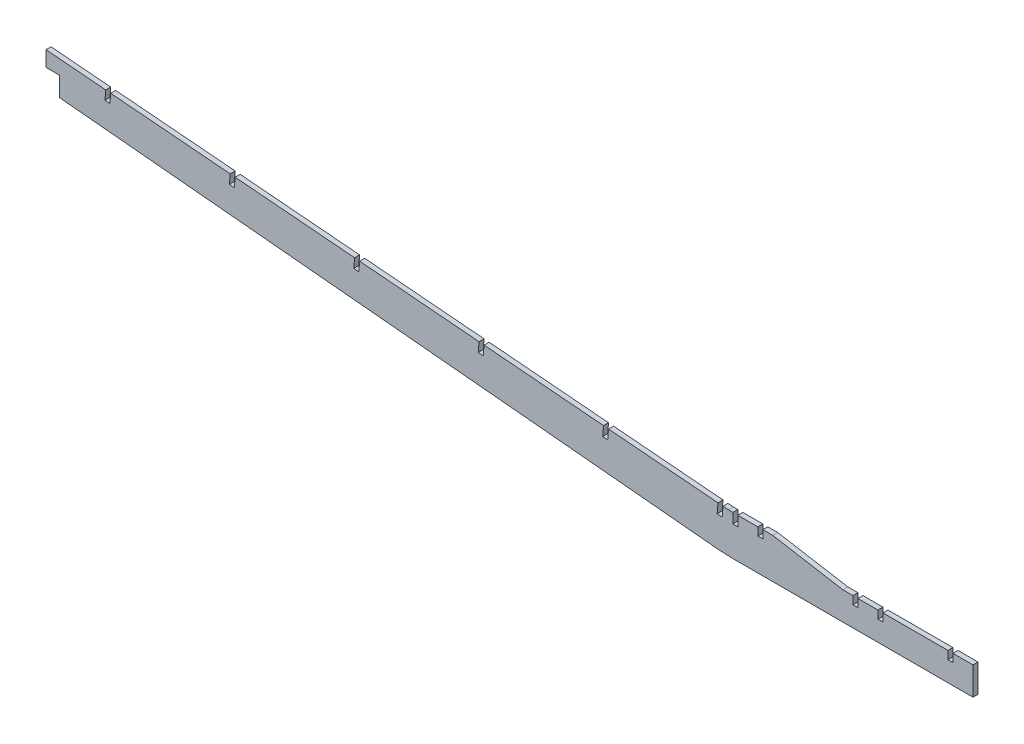
from build123d import *

# Parameters (mm, degrees)
BOSS_EXTRUDE1_DEPTH = 3.175
CUT_EXTRUDE1_DEPTH  = 4.175
CUT_EXTRUDE2_DEPTH  = 7.62


with BuildPart() as part:
    # Sketch1 → Boss-Extrude1 (new body)
    with BuildSketch(Plane.XY):
        Polygon((-950.530495659, 69.619322302), (-951.061849964, 63.291592645), (-11.536706102, -24.902638492), (-8.372841274, -25.168315645), (0, -25.545856054), (152.4, -25.545856054), (152.4, -7.765856054), (139.7, -7.765856054), (139.7, -12.845856054), (136.525, -12.845856054), (136.525, -7.765856054), (95.25, -7.765856054), (95.25, -12.845856054), (92.075, -12.845856054), (92.075, -7.765856054), (79.375, -7.765856054), (79.375, -12.845856054), (76.2, -12.845856054), (76.2, -7.765856054), (69.85, -7.765856054), (25.4, -0.145856054), (19.05, -0.145856054), (19.05, -5.225856054), (15.875, -5.225856054), (15.875, -0.145856054), (3.175, -0.145856054), (3.175, -6.495856054), (0, -6.495856054), (0, -0.145856054), (-2.81225704, -0.145856054), (-6.247424053, 0.14260298), (-6.778778359, -6.185126677), (-9.942643187, -5.919449524), (-9.411288881, 0.408280132), (-946.54805097, 79.101852726), (-947.366630831, 69.353645149), align=None)
    extrude(amount=BOSS_EXTRUDE1_DEPTH)

    # Sketch2 → Cut-Extrude1 (cut, through all)
    with BuildSketch(Plane.XY.offset(3.175)):
        Polygon((-869.047169109, 67.116306724), (-868.590421605, 72.555567687), (-871.754286433, 72.821244839), (-872.210759203, 67.385255598), align=None)
        Polygon((-790.083960364, 60.403342827), (-789.620355495, 65.924265958), (-792.784220323, 66.189943111), (-793.247550458, 60.672291701), align=None)
        Polygon((-711.120751618, 53.69037893), (-710.650289385, 59.29296423), (-713.814154213, 59.558641383), (-714.284341712, 53.959327804), align=None)
        Polygon((-632.157542872, 46.977415032), (-631.680223276, 52.661662502), (-634.844088104, 52.927339654), (-635.321132966, 47.246363906), align=None)
        Polygon((-553.194334126, 40.264451135), (-552.710157166, 46.030360773), (-555.874021994, 46.296037926), (-556.35792422, 40.533400009), align=None)
        Polygon((-474.23112538, 33.551487238), (-473.740091056, 39.399059045), (-476.903955884, 39.664736197), (-477.394715474, 33.820436112), align=None)
        Polygon((-395.267916634, 26.83852334), (-394.770024946, 32.767757316), (-397.933889774, 33.033434469), (-398.431506728, 27.107472214), align=None)
        Polygon((-316.304707888, 20.125559443), (-315.799958836, 26.136455588), (-318.963823664, 26.402132741), (-319.468297982, 20.394508317), align=None)
        Polygon((-237.341499142, 13.412595546), (-236.829892727, 19.50515386), (-239.993757555, 19.770831012), (-240.505089236, 13.68154442), align=None)
        Polygon((-158.378290396, 6.699631648), (-157.859826617, 12.873852131), (-161.023691445, 13.139529284), (-161.54188049, 6.968580522), align=None)
        Polygon((-79.415081651, -0.013332249), (-78.889760507, 6.242550403), (-82.053625335, 6.508227555), (-82.578671745, 0.255616625), align=None)
    extrude(amount=-CUT_EXTRUDE1_DEPTH, mode=Mode.SUBTRACT)

    # Sketch3 → Cut-Extrude2 (cut)
    with BuildSketch(Plane.XY.offset(3.175)):
        Polygon((-435.836990415, 36.216246757), (-435.836990415, 26.451619727), (-427.115588921, 26.451619727), (-427.115588921, 14.108196169), (-989.316849096, 0), (-981.213716068, 132.265755076), align=None)
    extrude(amount=-CUT_EXTRUDE2_DEPTH, mode=Mode.SUBTRACT)


solid = part.part
